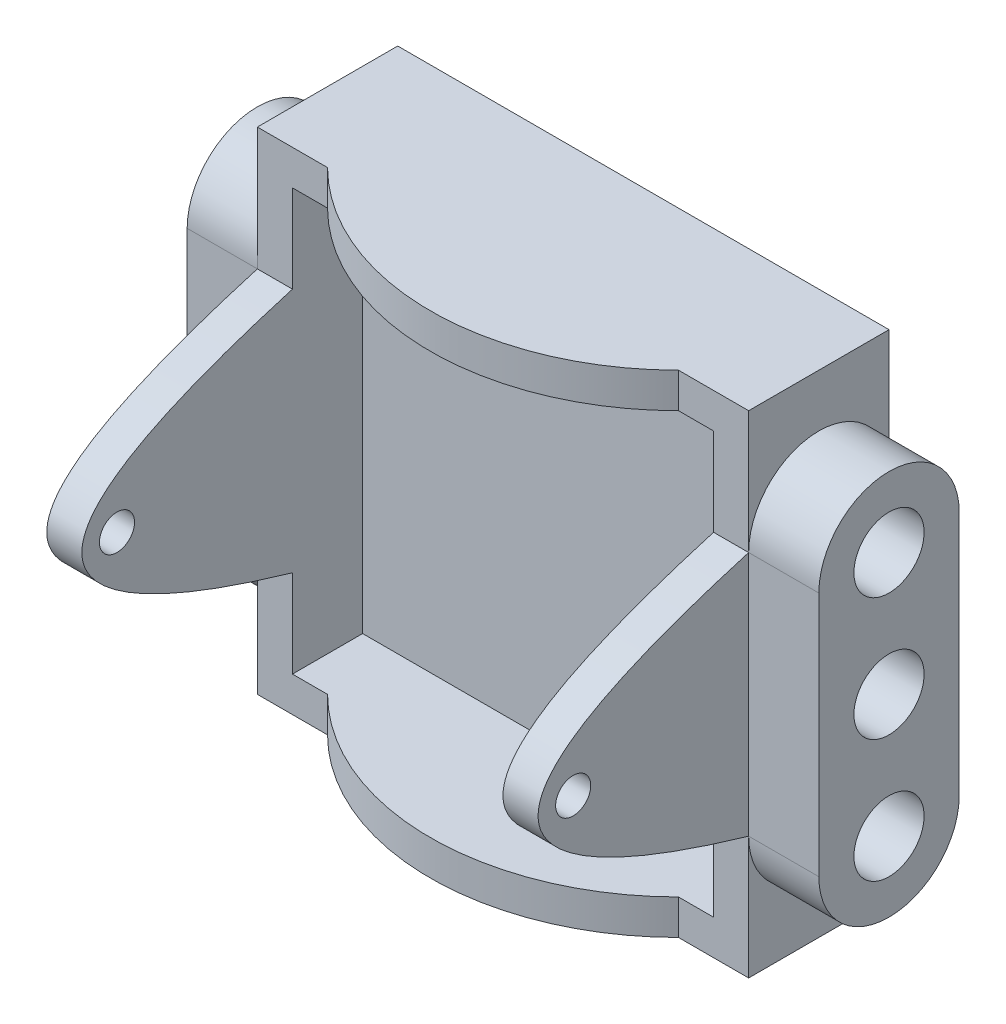
from build123d import *

# Parameters (mm, degrees)
SKETCH2_W           = 28.575
SKETCH2_H           = 22.225
BOSS_EXTRUDE1_DEPTH = 15.875
SKETCH5_W           = 19.05
SKETCH5_H           = 19.05
CUT_EXTRUDE3_DEPTH  = 12.7
SKETCH4_R           = 1.5875
CUT_EXTRUDE2_DEPTH  = 3.175
CUT_EXTRUDE1_DEPTH  = 23.225
SKETCH6_R           = 0.79375
CUT_EXTRUDE4_DEPTH  = 1.5875


with BuildPart() as part:
    # Sketch2 → Boss-Extrude1 (new body)
    with BuildSketch(Plane.XY):
        Rectangle(SKETCH2_W, SKETCH2_H)
    extrude(amount=BOSS_EXTRUDE1_DEPTH)

    # Sketch5 → Cut-Extrude3 (cut)
    with BuildSketch(Plane.XY.offset(15.875)):
        Rectangle(SKETCH5_W, SKETCH5_H)
    extrude(amount=-CUT_EXTRUDE3_DEPTH, mode=Mode.SUBTRACT)

    # Sketch4 → Cut-Extrude2 (cut)
    with BuildSketch(Plane.ZY.offset(14.2875)):
        with BuildLine():
            ThreePointArc((6.35, -5.55625), (3.175, -8.73125), (0, -5.55625))
            Line((0, -5.55625), (0, -11.1125))
            Line((0, -11.1125), (15.875, -11.1125))
            Line((15.875, -11.1125), (15.875, 11.1125))
            Line((15.875, 11.1125), (0, 11.1125))
            Line((0, 11.1125), (0, 5.55625))
            ThreePointArc((0, 5.55625), (3.175, 8.73125), (6.35, 5.55625))
            Line((6.35, 5.55625), (6.35, -5.55625))
        make_face()
        with Locations((3.175, 5.55625)):
            Circle(SKETCH4_R)
        with Locations((3.175, 0)):
            Circle(SKETCH4_R)
        with Locations((3.175, -5.55625)):
            Circle(SKETCH4_R)
    cut_extrude2 = extrude(amount=-CUT_EXTRUDE2_DEPTH, mode=Mode.SUBTRACT)

    # Mirror1: Cut-Extrude2 across plane
    add(cut_extrude2.mirror(Plane(origin=(0, 0, 0), x_dir=(0, 0, 1), z_dir=(1, 0, 0))), mode=Mode.SUBTRACT)

    # Sketch3 → Cut-Extrude1 (cut, through all)
    with BuildSketch(Plane(origin=(0, 11.1125, 0), x_dir=(1, 0, 0), z_dir=(0, 1, 0))):
        with BuildLine():
            Line((-7.9375, -6.35), (-9.525, -6.35))
            Line((-9.525, -6.35), (-9.525, -15.875))
            Line((-9.525, -15.875), (9.525, -15.875))
            Line((9.525, -15.875), (9.525, -6.35))
            Line((9.525, -6.35), (7.9375, -6.35))
            ThreePointArc((7.9375, -6.35), (0, -9.637820151), (-7.9375, -6.35))
        make_face()
    extrude(amount=-CUT_EXTRUDE1_DEPTH, mode=Mode.SUBTRACT)

    # Sketch6 → Cut-Extrude4 (cut)
    with BuildSketch(Plane.ZY.offset(11.1125)):
        with BuildLine():
            Line((15.875, -11.1125), (15.875, 0))
            add(Edge.make_bspline(
                [(6.35, -5.55625), (15.875, -2.778125), (15.875, 0)],
                knots=[0, 0, 0, 0.5, 0.5, 0.5], degree=2))
            Line((6.35, -5.55625), (6.35, -11.1125))
            Line((6.35, -11.1125), (15.875, -11.1125))
        make_face()
        with BuildLine():
            Line((6.35, 11.1125), (6.35, 5.55625))
            add(Edge.make_bspline(
                [(15.875, 0), (15.875, 2.778125), (6.35, 5.55625)],
                knots=[0.5, 0.5, 0.5, 1, 1, 1], degree=2))
            Line((15.875, 0), (15.875, 11.1125))
            Line((15.875, 11.1125), (6.35, 11.1125))
        make_face()
        with Locations((14.2875, 0)):
            Circle(SKETCH6_R)
    cut_extrude4 = extrude(amount=-CUT_EXTRUDE4_DEPTH, mode=Mode.SUBTRACT)

    # Mirror2: Cut-Extrude4 across plane
    add(cut_extrude4.mirror(Plane(origin=(0, 0, 0), x_dir=(0, 0, 1), z_dir=(1, 0, 0))), mode=Mode.SUBTRACT)


solid = part.part
